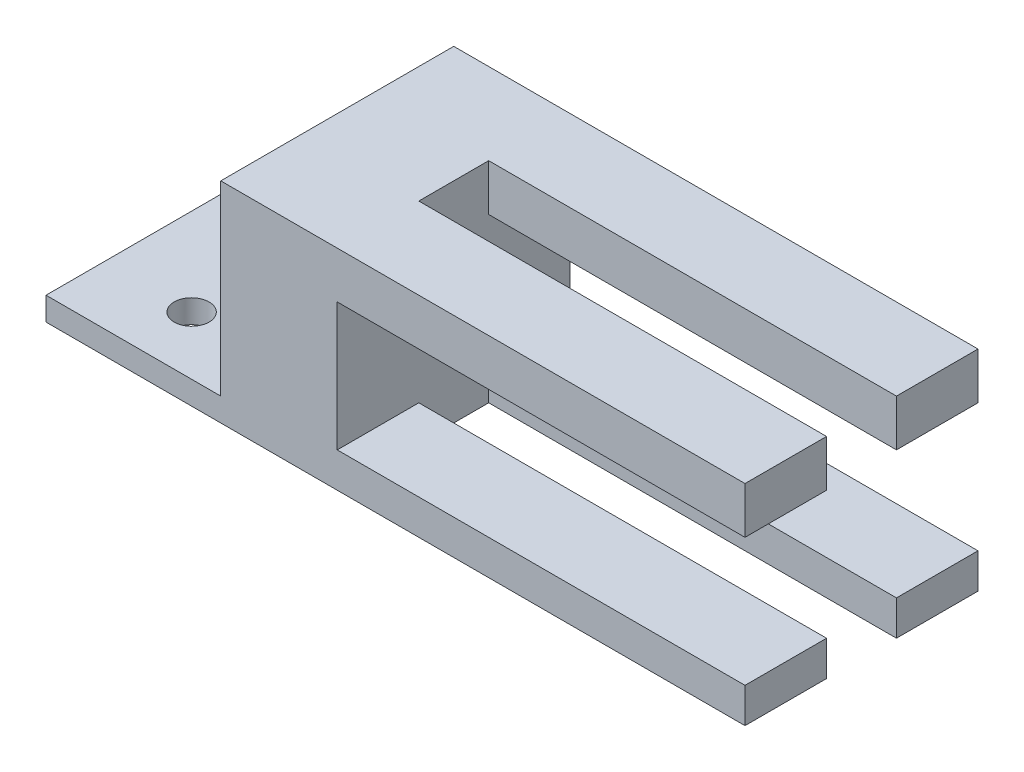
from build123d import *

# Parameters (mm, degrees)
BOSS_EXTRUDE1_DEPTH      = 10
BOSS_EXTRUDE1_DEPTH_BACK = 10
SKETCH1_W                = 10
SKETCH1_H                = 18
SKETCH2_W                = 20
SKETCH2_H                = 2
BOSS_EXTRUDE2_DEPTH      = 20
SKETCH3_W                = 7
SKETCH3_H                = 4
SKETCH3_H_2              = 3
BOSS_EXTRUDE3_DEPTH      = 40
SKETCH7_R                = 1.5
CUT_EXTRUDE2_DEPTH       = 10


with BuildPart() as part:
    # Sketch1 → Boss-Extrude1 (new, two sides: drawn at the far end of the back side and taken through both)
    with BuildSketch(Plane.XY.offset(-BOSS_EXTRUDE1_DEPTH_BACK)):
        with Locations((0, 6)):
            Rectangle(SKETCH1_W, SKETCH1_H)
    extrude(amount=BOSS_EXTRUDE1_DEPTH + BOSS_EXTRUDE1_DEPTH_BACK)

    # Sketch2 → Boss-Extrude2 (add)
    with BuildSketch(Plane(origin=(0, 0, 0), x_dir=(0, 0, -1), z_dir=(1, 0, 0))):
        with Locations((0, -2)):
            Rectangle(SKETCH2_W, SKETCH2_H)
    extrude(amount=-BOSS_EXTRUDE2_DEPTH)

    # Sketch3 → Boss-Extrude3 (add)
    with BuildSketch(Plane(origin=(0, 0, 0), x_dir=(0, 0, -1), z_dir=(1, 0, 0))):
        with Locations((-6.5, 13)):
            Rectangle(SKETCH3_W, SKETCH3_H)
        with Locations((-6.5, -1.5)):
            Rectangle(SKETCH3_W, SKETCH3_H_2)
        with Locations((6.5, -1.5)):
            Rectangle(SKETCH3_W, SKETCH3_H_2)
        with Locations((6.5, 13)):
            Rectangle(SKETCH3_W, SKETCH3_H)
    extrude(amount=BOSS_EXTRUDE3_DEPTH)

    # Sketch7 → Cut-Extrude2 (cut)
    with BuildSketch(Plane(origin=(0, 0, 0), x_dir=(1, 0, 0), z_dir=(0, 1, 0))):
        with Locations((-12.5, 5)):
            Circle(SKETCH7_R)
        with Locations((-12.5, -5)):
            Circle(SKETCH7_R)
    extrude(amount=-CUT_EXTRUDE2_DEPTH, mode=Mode.SUBTRACT)


solid = part.part
